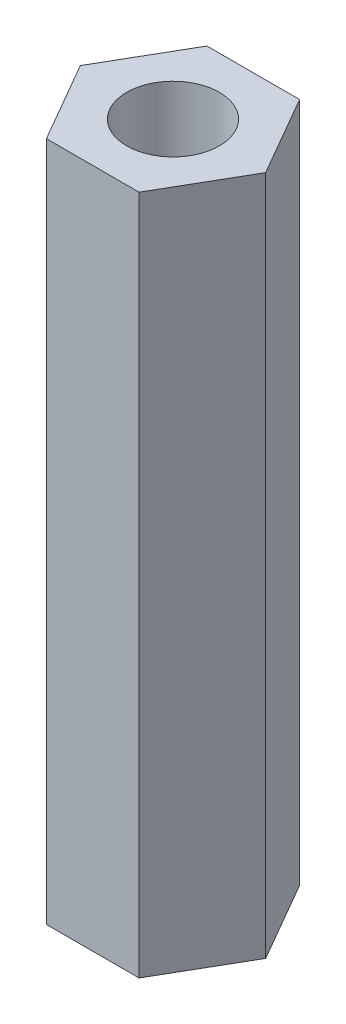
from build123d import *

# Parameters (mm, degrees)
SKETCH1_R           = 1.5
BOSS_EXTRUDE1_DEPTH = 22


with BuildPart() as part:
    # Sketch1 → Boss-Extrude1 (new body)
    with BuildSketch(Plane(origin=(0, 0, 0), x_dir=(1, 0, 0), z_dir=(0, 1, 0))):
        Polygon((2.99601055, 0), (1.498005275, 2.594621246), (-1.498005275, 2.594621246), (-2.99601055, 0), (-1.498005275, -2.594621246), (1.498005275, -2.594621246), align=None)
        Circle(SKETCH1_R, mode=Mode.SUBTRACT)
    extrude(amount=BOSS_EXTRUDE1_DEPTH)


solid = part.part
